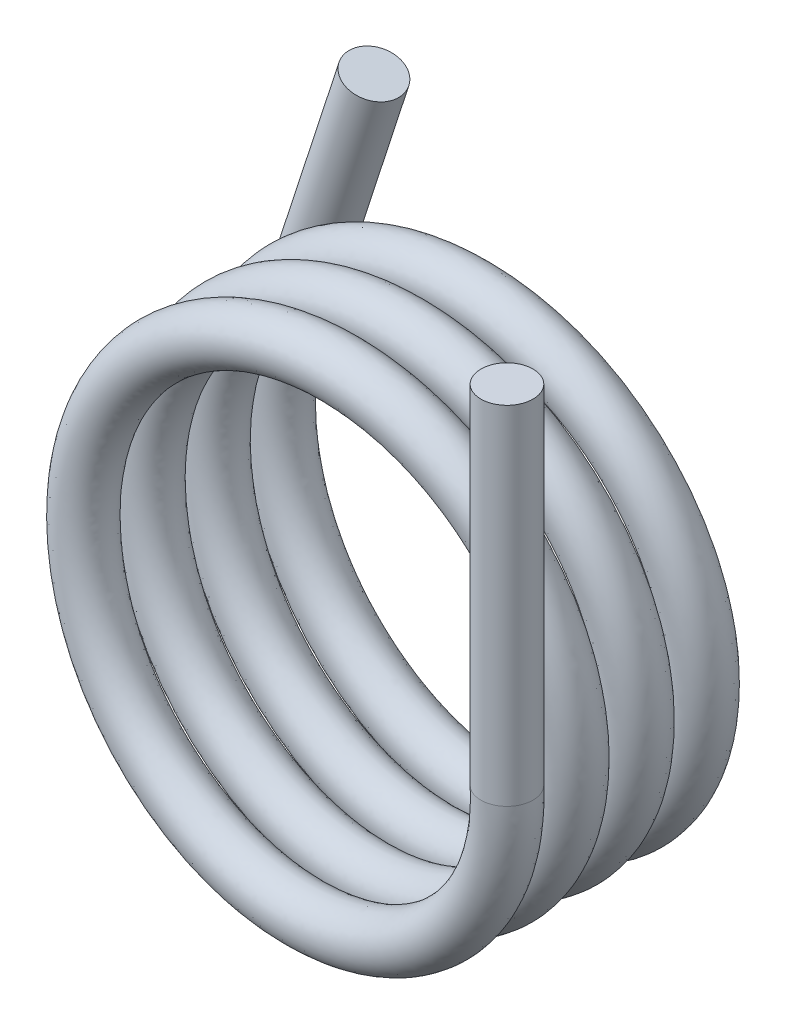
from build123d import *

# Parameters (mm, degrees)
SWEEP1_PITCH        = 0.75
SWEEP1_HEIGHT       = 2.6625
SWEEP1_RADIUS       = 2.625
SWEEP1_START_ANGLE  = 180
SKETCH2_R           = 0.3
SKETCH4_R           = 0.3
BOSS_EXTRUDE1_DEPTH = 3
SKETCH5_R           = 0.3
BOSS_EXTRUDE2_DEPTH = 4


with BuildPart() as part:
    # Sweep1: sweep along a helix
    with BuildLine() as sweep1_path:
        add(Helix(SWEEP1_PITCH, SWEEP1_HEIGHT, SWEEP1_RADIUS, center=(0, 0, 0), direction=(0, 0, -1), mode=Mode.PRIVATE).rotate(Axis((0, 0, 0), (0, 0, -1)), SWEEP1_START_ANGLE))
    # Sketch2 → Sweep1 (sweep)
    with BuildSketch(Plane(origin=(0, 0, 0), x_dir=(1, 0, 0), z_dir=(0, 1, 0))):
        with Locations((2.625, 0)):
            Circle(SKETCH2_R)
    sweep(path=sweep1_path.line, is_frenet=True)


with BuildPart() as boss_extrude1_tool:
    # Sketch4 → Boss-Extrude1 (new body)
    with BuildSketch(Plane(origin=(0, 0, 0), x_dir=(-0.951055229534023, 0.30902095459044027, 0), z_dir=(0.30902095459044027, 0.951055229534023, 0))):
        with Locations(Location((2.625, -2.662265032, 0), (0, 0, 90))):
            Circle(SKETCH4_R)
    extrude(amount=BOSS_EXTRUDE1_DEPTH)


with BuildPart() as part_1:
    add(part.part)


with BuildPart() as part_2:
    # Boss-Extrude1: joined with boss_extrude1_tool
    add(part_1.part.fuse(boss_extrude1_tool.part, tol=0.00001))

    # Sketch5 → Boss-Extrude2 (add)
    with BuildSketch(Plane(origin=(0, 0, 0), x_dir=(1, 0, 0), z_dir=(0, 1, 0))):
        with Locations(Location((2.625, 0, 0), (0, 0, 270))):
            Circle(SKETCH5_R)
    extrude(amount=BOSS_EXTRUDE2_DEPTH)


solid = part_2.part
